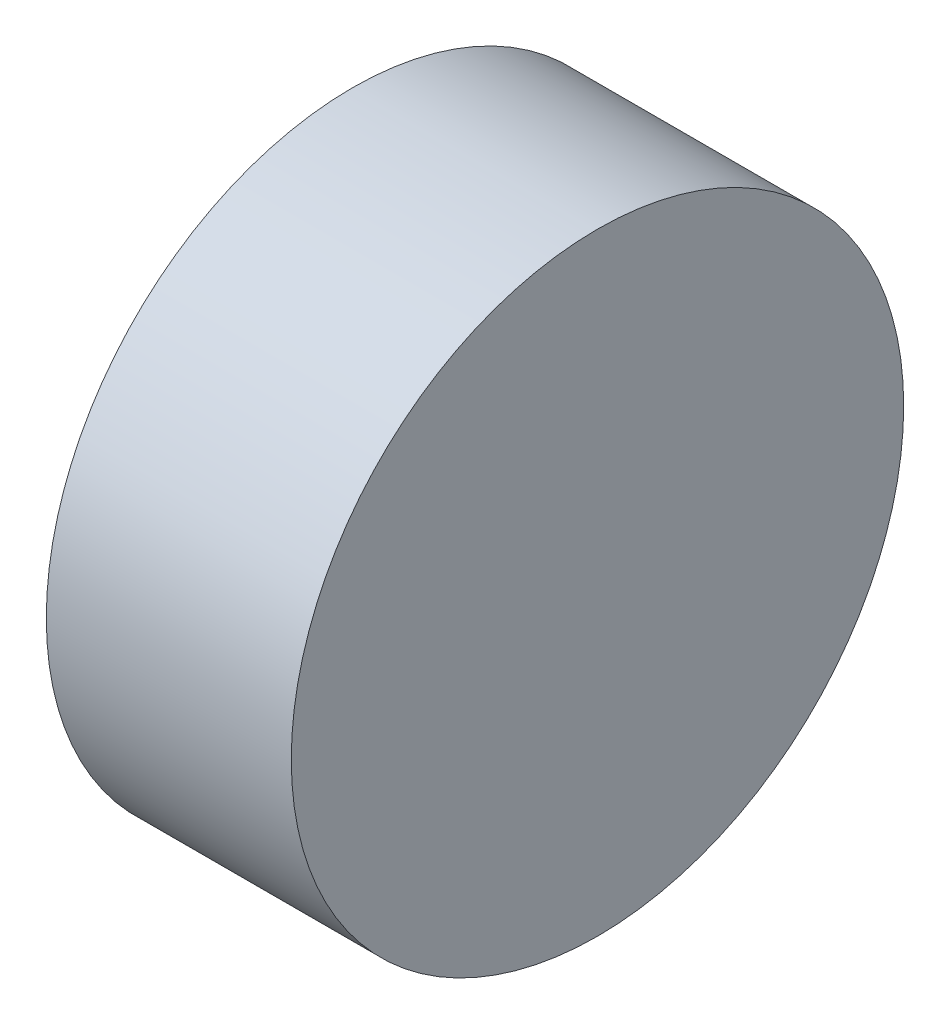
from build123d import *

# Parameters (mm, degrees)
SKETCH1_W = 20
SKETCH1_H = 25


with BuildPart() as part:
    # Sketch1 → Revolve1 (revolve)
    with BuildSketch(Plane.XY):
        with Locations((4.627659574, -3.430851064)):
            Rectangle(SKETCH1_W, SKETCH1_H)
    revolve(axis=Axis((14.627659574, 9.069148936, 0), (-1, 0, 0)))


solid = part.part
